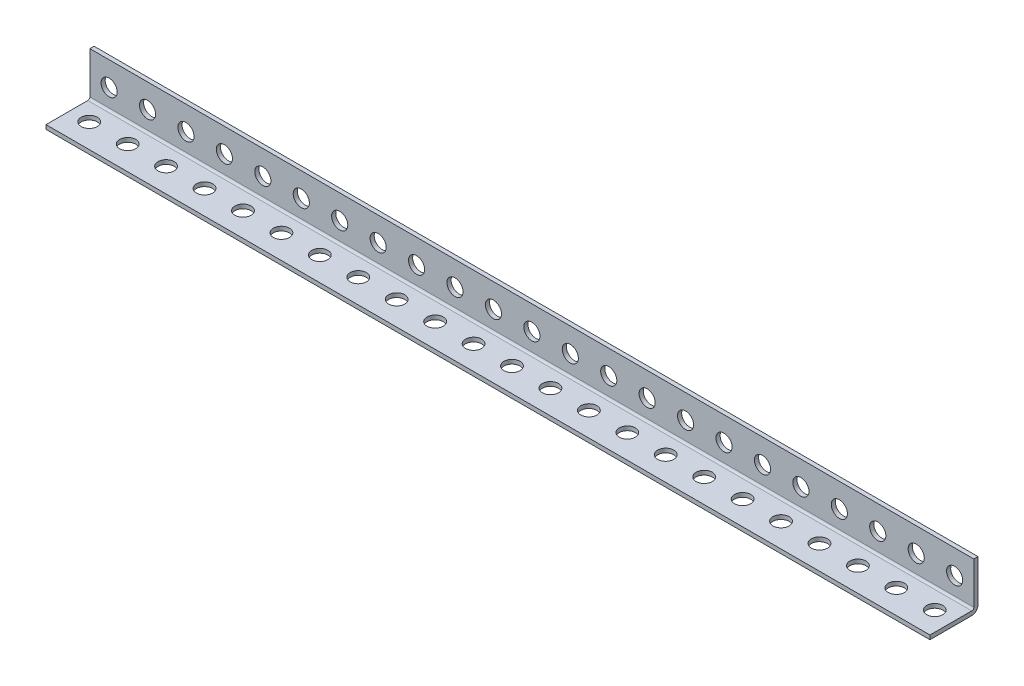
from build123d import *

# Parameters (mm, degrees)
BOSS_EXTRUDE1_DEPTH      = 609.6
BOSS_EXTRUDE1_DEPTH_BACK = 609.6
SKETCH5_R                = 5.334
CUT_EXTRUDE1_DEPTH       = 16.875
SKETCH6_R                = 5.334
CUT_EXTRUDE2_DEPTH       = 16.875
LPATTERN1_COUNT          = 48
LPATTERN1_PITCH          = 25.4
SKETCH7_W                = 635
SKETCH7_H                = 31.75
CUT_EXTRUDE3_DEPTH       = 70


with BuildPart() as part:
    # Sketch4 → Boss-Extrude1 (new body, two sides)
    with BuildSketch(Plane(origin=(0, 0, 0), x_dir=(0, 0, -1), z_dir=(1, 0, 0))) as boss_extrude1_sk:
        with BuildLine():
            Line((-15.875, -13.1318), (11.7602, -13.1318))
            ThreePointArc((11.7602, -13.1318), (12.730067661, -12.730067661), (13.1318, -11.7602))
            Line((13.1318, -11.7602), (13.1318, 15.875))
            Line((13.1318, 15.875), (15.875, 15.875))
            Line((15.875, 15.875), (15.875, -11.7602))
            ThreePointArc((15.875, -11.7602), (14.669802983, -14.669802983), (11.7602, -15.875))
            Line((11.7602, -15.875), (-15.875, -15.875))
            Line((-15.875, -15.875), (-15.875, -13.1318))
        make_face()
    extrude(amount=BOSS_EXTRUDE1_DEPTH)
    extrude(boss_extrude1_sk.sketch, amount=-BOSS_EXTRUDE1_DEPTH_BACK)

    # Sketch5 → Cut-Extrude1 (cut, through all)
    with BuildSketch(Plane.XY):
        with Locations((596.9, 0)):
            Circle(SKETCH5_R)
    cut_extrude1 = extrude(amount=-CUT_EXTRUDE1_DEPTH, mode=Mode.SUBTRACT)

    # Sketch6 → Cut-Extrude2 (cut, through all)
    with BuildSketch(Plane(origin=(0, 0, 0), x_dir=(1, 0, 0), z_dir=(0, 1, 0))):
        with Locations((596.9, 0)):
            Circle(SKETCH6_R)
    cut_extrude2 = extrude(amount=-CUT_EXTRUDE2_DEPTH, mode=Mode.SUBTRACT)

    # LPattern1: Cut-Extrude1, Cut-Extrude2 ×48
    with Locations(*[(-i * LPATTERN1_PITCH, 0, 0) for i in range(1, LPATTERN1_COUNT)]):
        add(cut_extrude1, mode=Mode.SUBTRACT)
        add(cut_extrude2, mode=Mode.SUBTRACT)

    # Sketch7 → Cut-Extrude3 (cut)
    with BuildSketch(Plane(origin=(0, 0, -15.875), x_dir=(-1, 0, 0), z_dir=(0, 0, -1))):
        with Locations((-292.1, 0)):
            Rectangle(SKETCH7_W, SKETCH7_H)
    extrude(amount=-CUT_EXTRUDE3_DEPTH, mode=Mode.SUBTRACT)


solid = part.part
